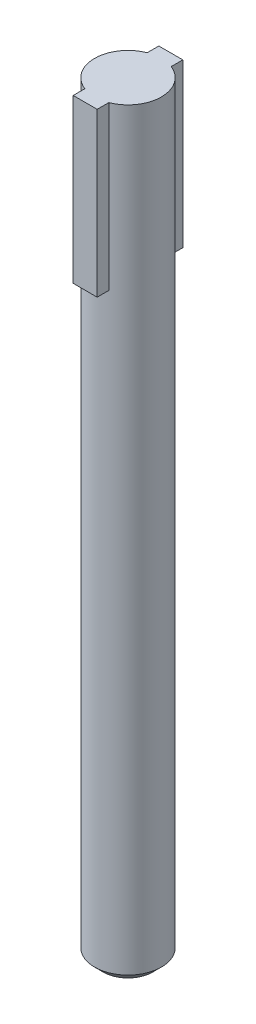
from build123d import *

# Parameters (mm, degrees)
ESQUISSE1_R             = 3.9
BOSS_EXTRU_1_DEPTH      = 8
BOSS_EXTRU_1_DEPTH_BACK = 81
BOSS_EXTRU_2_DEPTH      = 19
CHANFREIN1_SIZE         = 1


with BuildPart() as part:
    # Esquisse1 → Boss.-Extru.1 (new body, two sides)
    with BuildSketch(Plane(origin=(0, 0, 0), x_dir=(1, 0, 0), z_dir=(0, 1, 0))) as boss_extru_1_sk:
        Circle(ESQUISSE1_R)
    extrude(amount=BOSS_EXTRU_1_DEPTH)
    extrude(boss_extru_1_sk.sketch, amount=-BOSS_EXTRU_1_DEPTH_BACK)

    # Esquisse2 → Boss.-Extru.2 (add)
    with BuildSketch(Plane(origin=(0, 8, 0), x_dir=(1, 0, 0), z_dir=(0, 1, 0))):
        with BuildLine():
            Line((-1.4, 5), (-1.4, 3.640054945))
            ThreePointArc((-1.4, 3.640054945), (0, 3.9), (1.4, 3.640054945))
            Line((1.4, 3.640054945), (1.4, 5))
            Line((1.4, 5), (-1.4, 5))
        make_face()
        with BuildLine():
            ThreePointArc((1.4, -3.640054945), (0, -3.9), (-1.4, -3.640054945))
            Line((-1.4, -3.640054945), (-1.4, -5))
            Line((-1.4, -5), (1.4, -5))
            Line((1.4, -5), (1.4, -3.640054945))
        make_face()
        with BuildLine():
            Line((-1.4, 3.640054945), (-1.4, 0))
            Line((-1.4, 0), (1.4, 0))
            Line((1.4, 0), (1.4, 3.640054945))
            ThreePointArc((1.4, 3.640054945), (0, 3.9), (-1.4, 3.640054945))
        make_face()
        with BuildLine():
            Line((1.4, 0), (-1.4, 0))
            Line((-1.4, 0), (-1.4, -3.640054945))
            ThreePointArc((-1.4, -3.640054945), (0, -3.9), (1.4, -3.640054945))
            Line((1.4, -3.640054945), (1.4, 0))
        make_face()
    extrude(amount=-BOSS_EXTRU_2_DEPTH)

    # Chanfrein1
    chanfrein1_edges = [part.edges().sort_by_distance(p)[0] for p in [
        (-3.9, -81, 0),
    ]]
    chamfer(chanfrein1_edges, length=CHANFREIN1_SIZE)


solid = part.part
